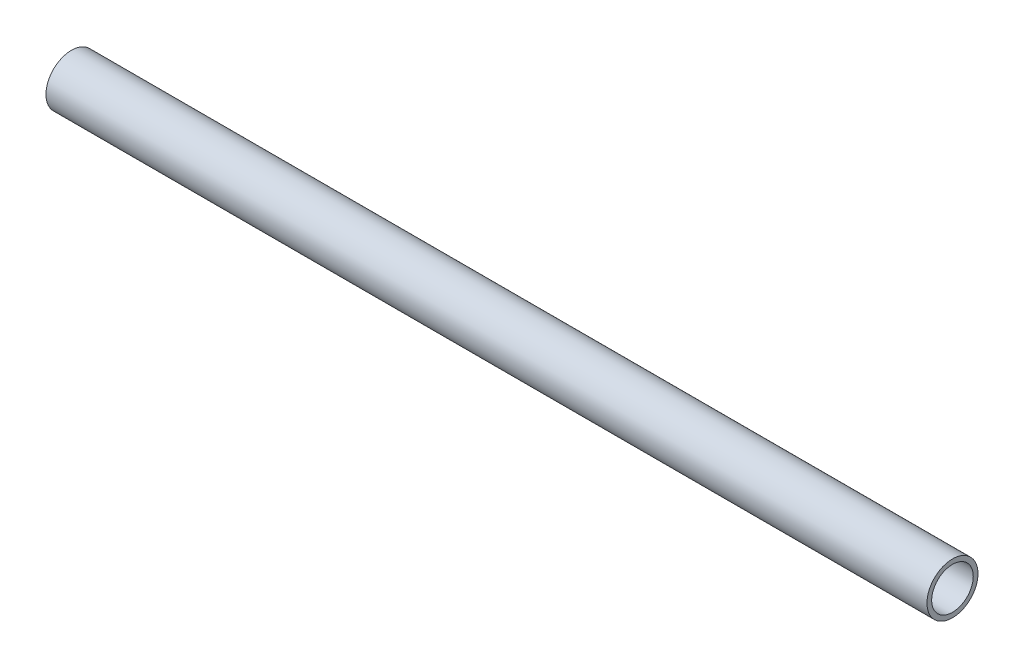
from build123d import *

# Parameters (mm, degrees)
SKETCH11_R               = 7.9375
SKETCH11_R_2             = 6.4643
STRUCTURAL_MEMBER1_DEPTH = 273.9898


with BuildPart() as part:
    # Sketch11 → Structural Member1 (new body)
    with BuildSketch(Plane.YZ):
        Circle(SKETCH11_R)
        Circle(SKETCH11_R_2, mode=Mode.SUBTRACT)
    extrude(amount=STRUCTURAL_MEMBER1_DEPTH)


solid = part.part
